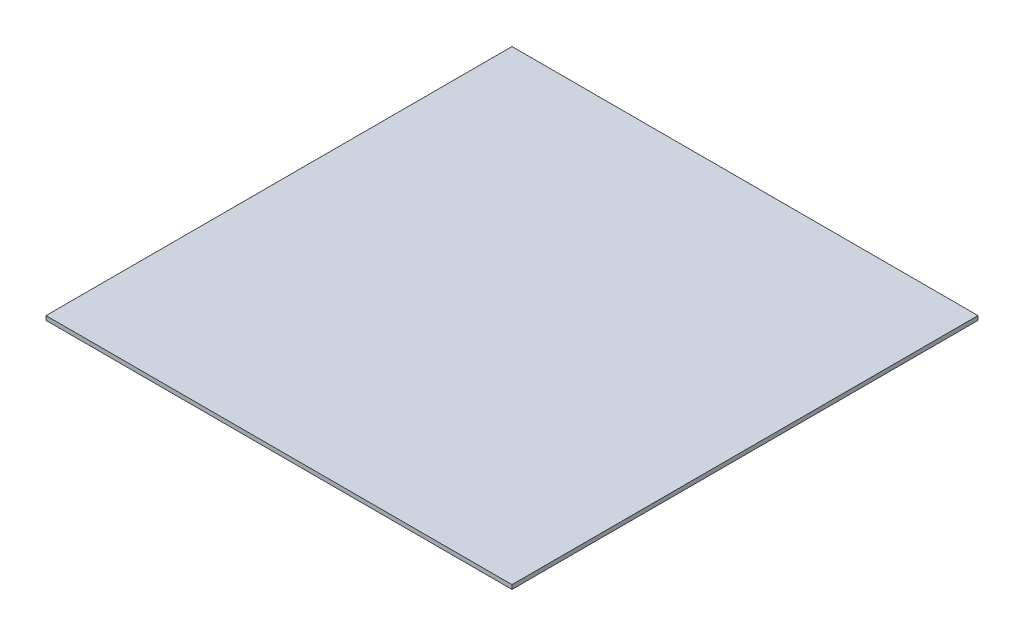
from build123d import *

# Parameters (mm, degrees)
SKETCH1_W           = 500
SKETCH1_H           = 500
BOSS_EXTRUDE1_DEPTH = 4.5


with BuildPart() as part:
    # Sketch1 → Boss-Extrude1 (new body)
    with BuildSketch(Plane(origin=(0, 0, 0), x_dir=(1, 0, 0), z_dir=(0, 1, 0))):
        Rectangle(SKETCH1_W, SKETCH1_H)
    extrude(amount=BOSS_EXTRUDE1_DEPTH)


solid = part.part
